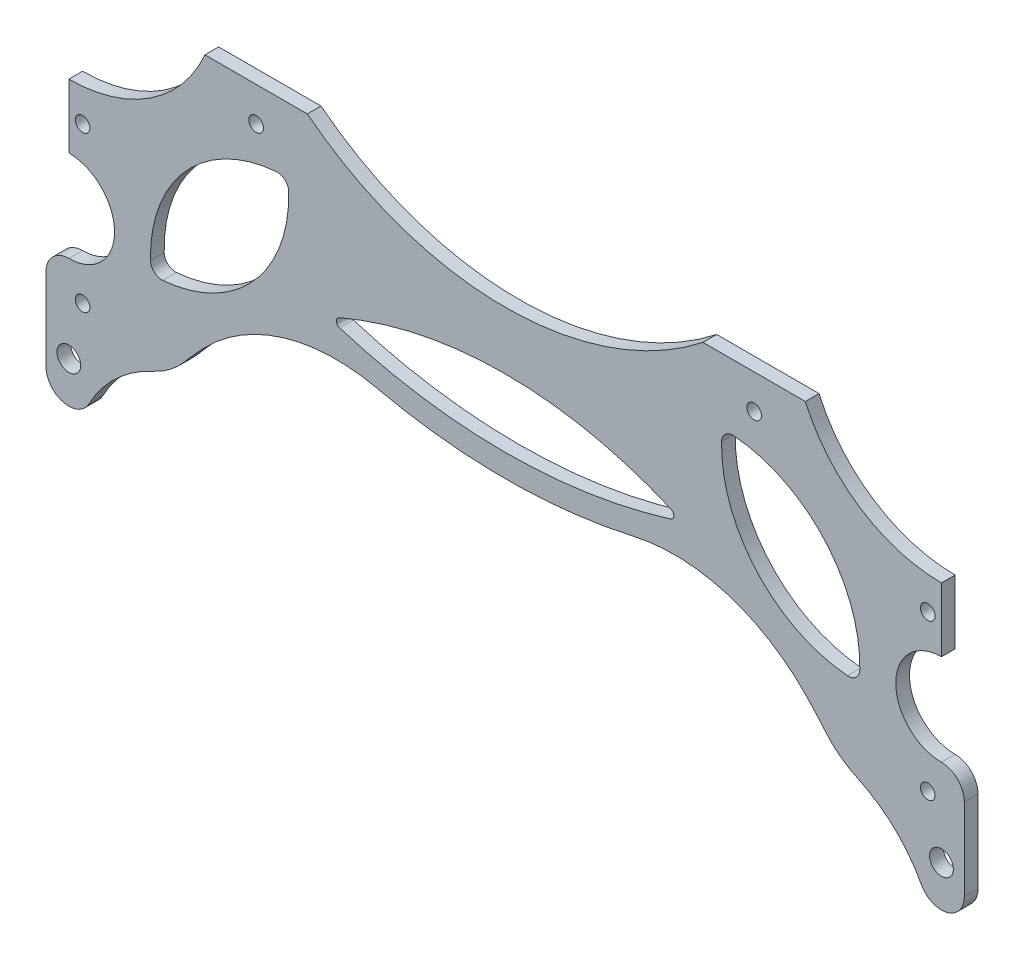
from build123d import *

# Parameters (mm, degrees)
EXTRUDE_1_DEPTH     = 3
EXTRUDE_1_2_DEPTH   = 3
FILLET_1_R          = 40
CUT_EXTRUDE_1_REACH = 5
FILLET_2_R          = 20
CUT_EXTRUDE_2_REACH = 5
SKETCH_4_R          = 1.6
CUT_EXTRUDE_3_REACH = 5
SKETCH_5_R          = 1.6
FILLET_3_R          = 1
SKETCH_6_R          = 1.6
SKETCH_6_R_2        = 2.6
EXTRUDE_2_DEPTH     = 3
FILLET_4_R          = 30
FILLET_5_R          = 2.5


with BuildPart() as part:
    # 草图1 → Extrude 1 (new body)
    with BuildSketch(Plane.XY):
        with BuildLine():
            ThreePointArc((-43.301270189, 33.75), (0, 18.75), (43.301270189, 33.75))
            Line((43.301270189, 33.75), (65.713257983, 33.75))
            ThreePointArc((65.713257983, 33.75), (77.699016881, 19.558549138), (95.5, 14.25))
            Line((95.5, 14.25), (95.5, 0.25))
            ThreePointArc((95.5, 0.25), (85.5, -9.75), (95.5, -19.75))
            Line((95.5, -19.75), (95.5, -33.75))
            Line((95.5, -33.75), (75.5, -33.75))
            ThreePointArc((75.5, -33.75), (0, 6.139830406), (-75.5, -33.75))
            Line((-75.5, -33.75), (-95.5, -33.75))
            Line((-95.5, -33.75), (-95.5, -19.75))
            ThreePointArc((-95.5, -19.75), (-85.5, -9.75), (-95.5, 0.25))
            Line((-95.5, 0.25), (-95.5, 14.25))
            ThreePointArc((-95.5, 14.25), (-77.699016881, 19.558549138), (-65.713257983, 33.75))
            Line((-65.713257983, 33.75), (-43.301270189, 33.75))
        make_face()
    extrude(amount=EXTRUDE_1_DEPTH)

    # 草图2 → Extrude 1 2 (add)
    with BuildSketch(Plane.XY.offset(3)):
        with BuildLine():
            ThreePointArc((-73.077723915, 9.270833333), (1.020159466, -13.745918659), (74.740241536, 10.453599796))
            Line((74.740241536, 10.453599796), (71.809251672, 14.50443902))
            ThreePointArc((71.809251672, 14.50443902), (0.980153213, -8.746078711), (-70.211930821, 13.368055556))
            Line((-70.211930821, 13.368055556), (-73.077723915, 9.270833333))
        make_face()
    extrude(amount=-EXTRUDE_1_2_DEPTH)

    # 圆角1
    fillet_1_edges = [part.edges().sort_by_distance(p)[0] for p in [
        (44.828445276, -5.609375393, 1.5),
        (-44.828445276, -5.609375393, 1.5),
    ]]
    fillet(fillet_1_edges, radius=FILLET_1_R)

    # 草图3 → 切除-拉伸1 (cut, up to next)
    with BuildSketch(Plane.XY.offset(3), mode=Mode.PRIVATE) as cut_extrude_1_sk1:
        with BuildLine():
            ThreePointArc((-77.464525403, -13.719576202), (-55.070861932, -3.793658796), (-47.54009497, 19.514870736))
            ThreePointArc((-47.54009497, 19.514870736), (-69.933758441, 9.588953331), (-77.464525403, -13.719576202))
        make_face()
    cut_extrude_1_tool1 = extrude(cut_extrude_1_sk1.sketch, amount=-CUT_EXTRUDE_1_REACH, mode=Mode.PRIVATE) & part.part
    add(cut_extrude_1_tool1.solids().sort_by_distance((-62.50231, 2.897647, 3))[0], mode=Mode.SUBTRACT)
    # 草图3 → 切除-拉伸1 (cut, up to next)
    with BuildSketch(Plane.XY.offset(3), mode=Mode.PRIVATE) as cut_extrude_1_sk2:
        with BuildLine():
            ThreePointArc((77.464525403, -13.719576202), (69.933758441, 9.588953331), (47.54009497, 19.514870736))
            ThreePointArc((47.54009497, 19.514870736), (55.070861932, -3.793658796), (77.464525403, -13.719576202))
        make_face()
    cut_extrude_1_tool2 = extrude(cut_extrude_1_sk2.sketch, amount=-CUT_EXTRUDE_1_REACH, mode=Mode.PRIVATE) & part.part
    add(cut_extrude_1_tool2.solids().sort_by_distance((62.50231, 2.897647, 3))[0], mode=Mode.SUBTRACT)

    # 圆角2
    fillet_2_edges = [part.edges().sort_by_distance(p)[0] for p in [
        (75.5, -33.75, 1.5),
        (-75.5, -33.75, 1.5),
    ]]
    fillet(fillet_2_edges, radius=FILLET_2_R)

    # 草图4 → 切除-拉伸2 (cut, up to next)
    with BuildSketch(Plane.XY.offset(3), mode=Mode.PRIVATE) as cut_extrude_2_sk1:
        with Locations((-92.5, -26.75)):
            Circle(SKETCH_4_R)
    cut_extrude_2_tool1 = extrude(cut_extrude_2_sk1.sketch, amount=-CUT_EXTRUDE_2_REACH, mode=Mode.PRIVATE) & part.part
    add(cut_extrude_2_tool1.solids().sort_by_distance((-92.5, -26.75, 3))[0], mode=Mode.SUBTRACT)
    # 草图4 → 切除-拉伸2 (cut, up to next)
    with BuildSketch(Plane.XY.offset(3), mode=Mode.PRIVATE) as cut_extrude_2_sk2:
        with Locations((-92.5, 7.25)):
            Circle(SKETCH_4_R)
    cut_extrude_2_tool2 = extrude(cut_extrude_2_sk2.sketch, amount=-CUT_EXTRUDE_2_REACH, mode=Mode.PRIVATE) & part.part
    add(cut_extrude_2_tool2.solids().sort_by_distance((-92.5, 7.25, 3))[0], mode=Mode.SUBTRACT)
    # 草图4 → 切除-拉伸2 (cut, up to next)
    with BuildSketch(Plane.XY.offset(3), mode=Mode.PRIVATE) as cut_extrude_2_sk3:
        with Locations((92.5, 7.25)):
            Circle(SKETCH_4_R)
    cut_extrude_2_tool3 = extrude(cut_extrude_2_sk3.sketch, amount=-CUT_EXTRUDE_2_REACH, mode=Mode.PRIVATE) & part.part
    add(cut_extrude_2_tool3.solids().sort_by_distance((92.5, 7.25, 3))[0], mode=Mode.SUBTRACT)
    # 草图4 → 切除-拉伸2 (cut, up to next)
    with BuildSketch(Plane.XY.offset(3), mode=Mode.PRIVATE) as cut_extrude_2_sk4:
        with Locations((92.5, -26.75)):
            Circle(SKETCH_4_R)
    cut_extrude_2_tool4 = extrude(cut_extrude_2_sk4.sketch, amount=-CUT_EXTRUDE_2_REACH, mode=Mode.PRIVATE) & part.part
    add(cut_extrude_2_tool4.solids().sort_by_distance((92.5, -26.75, 3))[0], mode=Mode.SUBTRACT)

    # 草图5 → 切除-拉伸3 (cut, up to next)
    with BuildSketch(Plane.XY.offset(3), mode=Mode.PRIVATE) as cut_extrude_3_sk1:
        with Locations((-54.507264086, 26.25)):
            Circle(SKETCH_5_R)
    cut_extrude_3_tool1 = extrude(cut_extrude_3_sk1.sketch, amount=-CUT_EXTRUDE_3_REACH, mode=Mode.PRIVATE) & part.part
    add(cut_extrude_3_tool1.solids().sort_by_distance((-54.507264, 26.25, 3))[0], mode=Mode.SUBTRACT)
    # 草图5 → 切除-拉伸3 (cut, up to next)
    with BuildSketch(Plane.XY.offset(3), mode=Mode.PRIVATE) as cut_extrude_3_sk2:
        with Locations((54.507264086, 26.25)):
            Circle(SKETCH_5_R)
    cut_extrude_3_tool2 = extrude(cut_extrude_3_sk2.sketch, amount=-CUT_EXTRUDE_3_REACH, mode=Mode.PRIVATE) & part.part
    add(cut_extrude_3_tool2.solids().sort_by_distance((54.507264, 26.25, 3))[0], mode=Mode.SUBTRACT)

    # 圆角3
    fillet_3_edges = [part.edges().sort_by_distance(p)[0] for p in [
        (38.722757726, -2.468750785, 1.5),
        (-38.722757726, -2.468750785, 1.5),
    ]]
    fillet(fillet_3_edges, radius=FILLET_3_R)

    # 草图6 → 凸台-拉伸2 (add)
    with BuildSketch(Plane.XY.offset(3)):
        with BuildLine():
            Line((-90.5, -24.75), (-90.5, -42.75))
            ThreePointArc((-90.5, -42.75), (-95.5, -47.75), (-100.5, -42.75))
            Line((-100.5, -42.75), (-100.5, -24.75))
            ThreePointArc((-100.5, -24.75), (-95.5, -19.75), (-90.5, -24.75))
        make_face()
        with Locations((-92.5, -26.75)):
            Circle(SKETCH_6_R, mode=Mode.SUBTRACT)
        with Locations((-95.5, -38.75)):
            Circle(SKETCH_6_R_2, mode=Mode.SUBTRACT)
        with BuildLine():
            Line((90.5, -24.75), (90.5, -42.75))
            ThreePointArc((90.5, -42.75), (95.5, -47.75), (100.5, -42.75))
            Line((100.5, -42.75), (100.5, -24.75))
            ThreePointArc((100.5, -24.75), (95.5, -19.75), (90.5, -24.75))
        make_face()
        with Locations((92.5, -26.75)):
            Circle(SKETCH_6_R, mode=Mode.SUBTRACT)
        with Locations((95.5, -38.75)):
            Circle(SKETCH_6_R_2, mode=Mode.SUBTRACT)
    extrude(amount=-EXTRUDE_2_DEPTH)

    # 圆角4
    fillet_4_edges = [part.edges().sort_by_distance(p)[0] for p in [
        (90.5, -33.75, 1.5),
        (-90.5, -33.75, 1.5),
    ]]
    fillet(fillet_4_edges, radius=FILLET_4_R)

    # 圆角5
    fillet_5_edges = [part.edges().sort_by_distance(p)[0] for p in [
        (-77.464525403, -13.719576202, 1.5),
        (-47.54009497, 19.514870736, 1.5),
        (77.464525403, -13.719576202, 1.5),
        (47.54009497, 19.514870736, 1.5),
    ]]
    fillet(fillet_5_edges, radius=FILLET_5_R)


solid = part.part
